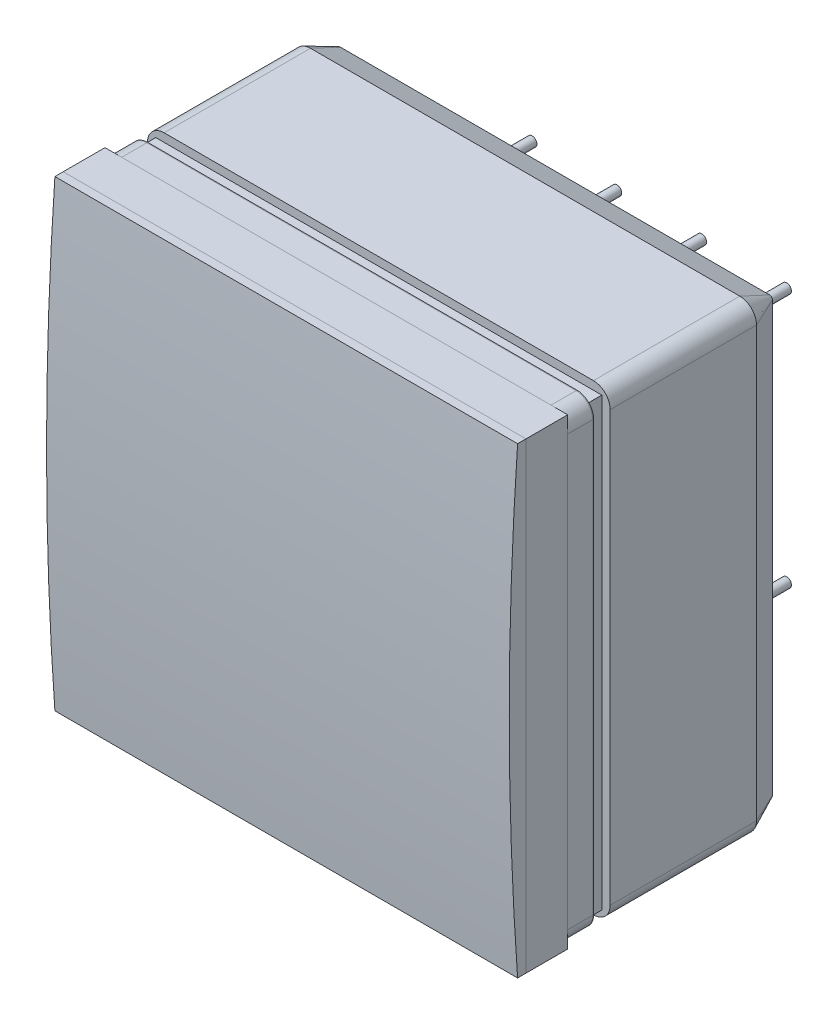
from build123d import *

# Parameters (mm, degrees)
METAL_CASE_AT_HV_DEPTH   = 8.76
SKETCH3_W                = 24.737677246
SKETCH3_H                = 24.830501551
PHOTOCATHODE_DEPTH       = 0.1
SKETCH5_W                = 26.7
SKETCH5_H                = 26.7
SKETCH5_W_2              = 23.2
SKETCH5_H_2              = 23.2
BOSS_EXTRUDE3_DEPTH      = 0.99
SKETCH6_W                = 23.2
SKETCH6_H                = 23.2
MIRRORED_SURFACE_DEPTH   = 0.05
FRONT_GLASS_DEPTH        = 1.5
SKETCH8_R                = 0.285
PINS_DEPTH               = 5.5
SKETCH9_W                = 1.403236588
SKETCH9_H                = 1.496318302
SKETCH9_W_2              = 1.502916358
SKETCH9_H_2              = 1.880163391
SKETCH9_W_3              = 1.432017479
SKETCH9_W_4              = 4.227959696
SKETCH9_W_5              = 1.836353851
SKETCH9_H_3              = 11.695124286
SKETCH9_H_4              = 4.871079897
SKETCH9_W_6              = 1.828629866
SKETCH9_H_5              = 1.71959621
SKETCH9_W_7              = 1.615933227
SKETCH9_W_8              = 1.365330314
SKETCH9_W_9              = 1.525378005
SKETCH9_H_6              = 1.496732956
SKETCH9_W_10             = 17.055037943
SKETCH9_H_7              = 1.444241572
SKETCH9_H_8              = 1.617700465
SKETCH9_H_9              = 1.513765196
SKETCH9_H_10             = 14.892572142
SKETCH9_H_11             = 1.645870576
SKETCH9_H_12             = 1.829290868
SKETCH9_W_11             = 1.140707165
SKETCH9_H_13             = 1.492116291
SKETCH9_W_12             = 1.724036428
SKETCH9_W_13             = 1.316199483
SKETCH9_H_14             = 1.570615298
SKETCH9_W_14             = 1.593474923
SKETCH9_W_15             = 1.889006141
SKETCH9_H_15             = 2.206356806
SKETCH9_W_16             = 6.877190486
SKETCH9_H_16             = 1.783898062
SKETCH9_W_17             = 1.759836844
SKETCH9_H_17             = 1.481039903
CUT_EXTRUDE1_DEPTH       = 5.5
RUBBER_DEPTH             = 1.79
RUBBER_TAPER             = 25
SKETCH17_W               = 27.7
SKETCH17_H               = 27.7
FILTER_2_DEPTH           = 2.5
COOKIE_CYLINDRICAL_DEPTH = 27.7


with BuildPart() as part:
    # Sketch2 → metal-case-at-HV (new body)
    with BuildSketch(Plane.XY.offset(-2.54)):
        with BuildLine():
            Line((1, 27.7), (26.7, 27.7))
            ThreePointArc((26.7, 27.7), (27.407106781, 27.407106781), (27.7, 26.7))
            Line((27.7, 26.7), (27.7, 1))
            ThreePointArc((27.7, 1), (27.407106781, 0.292893219), (26.7, 0))
            Line((26.7, 0), (1, 0))
            ThreePointArc((1, 0), (0.292893219, 0.292893219), (0, 1))
            Line((0, 1), (0, 26.7))
            ThreePointArc((0, 26.7), (0.292893219, 27.407106781), (1, 27.7))
        make_face()
    extrude(amount=-METAL_CASE_AT_HV_DEPTH)

    # Sketch3 → photocathode (add)
    with BuildSketch(Plane.XY.offset(-2.54)):
        with Locations((13.757175695, 13.780381772)):
            Rectangle(SKETCH3_W, SKETCH3_H)
    extrude(amount=PHOTOCATHODE_DEPTH)

    # Sketch5 → Boss-Extrude3 (add)
    with BuildSketch(Plane.XY.offset(-2.54)):
        with Locations((13.85, 13.85)):
            Rectangle(SKETCH5_W, SKETCH5_H)
        with Locations((13.85, 13.85)):
            Rectangle(SKETCH5_W_2, SKETCH5_H_2, mode=Mode.SUBTRACT)
    extrude(amount=BOSS_EXTRUDE3_DEPTH)

    # Sketch6 → mirrored-surface (add)
    with BuildSketch(Plane.XY.offset(-1.55)):
        with BuildLine():
            Line((1, 27.7), (26.7, 27.7))
            ThreePointArc((26.7, 27.7), (27.407106781, 27.407106781), (27.7, 26.7))
            Line((27.7, 26.7), (27.7, 1))
            ThreePointArc((27.7, 1), (27.407106781, 0.292893219), (26.7, 0))
            Line((26.7, 0), (1, 0))
            ThreePointArc((1, 0), (0.292893219, 0.292893219), (0, 1))
            Line((0, 1), (0, 26.7))
            ThreePointArc((0, 26.7), (0.292893219, 27.407106781), (1, 27.7))
        make_face()
        with Locations((13.85, 13.85)):
            Rectangle(SKETCH6_W, SKETCH6_H, mode=Mode.SUBTRACT)
    extrude(amount=MIRRORED_SURFACE_DEPTH)

    # Sketch8 → pins (add)
    with BuildSketch(Plane(origin=(0, 0, -11.3), x_dir=(-1, 0, 0), z_dir=(0, 0, -1))):
        with Locations((-24.01, 3.69)):
            Circle(SKETCH8_R)
        with Locations((-21.47, 3.69)):
            Circle(SKETCH8_R)
        with Locations((-18.93, 3.69)):
            Circle(SKETCH8_R)
        with Locations((-16.39, 3.69)):
            Circle(SKETCH8_R)
        with Locations((-13.85, 3.69)):
            Circle(SKETCH8_R)
        with Locations((-11.31, 3.69)):
            Circle(SKETCH8_R)
        with Locations((-8.77, 3.69)):
            Circle(SKETCH8_R)
        with Locations((-6.23, 3.69)):
            Circle(SKETCH8_R)
        with Locations((-3.69, 3.69)):
            Circle(SKETCH8_R)
        with Locations((-24.01, 6.23)):
            Circle(SKETCH8_R)
        with Locations((-21.47, 6.23)):
            Circle(SKETCH8_R)
        with Locations((-18.93, 6.23)):
            Circle(SKETCH8_R)
        with Locations((-16.39, 6.23)):
            Circle(SKETCH8_R)
        with Locations((-13.85, 6.23)):
            Circle(SKETCH8_R)
        with Locations((-11.31, 6.23)):
            Circle(SKETCH8_R)
        with Locations((-8.77, 6.23)):
            Circle(SKETCH8_R)
        with Locations((-6.23, 6.23)):
            Circle(SKETCH8_R)
        with Locations((-3.69, 6.23)):
            Circle(SKETCH8_R)
        with Locations((-24.01, 8.77)):
            Circle(SKETCH8_R)
        with Locations((-21.47, 8.77)):
            Circle(SKETCH8_R)
        with Locations((-18.93, 8.77)):
            Circle(SKETCH8_R)
        with Locations((-16.39, 8.77)):
            Circle(SKETCH8_R)
        with Locations((-13.85, 8.77)):
            Circle(SKETCH8_R)
        with Locations((-11.31, 8.77)):
            Circle(SKETCH8_R)
        with Locations((-8.77, 8.77)):
            Circle(SKETCH8_R)
        with Locations((-6.23, 8.77)):
            Circle(SKETCH8_R)
        with Locations((-3.69, 8.77)):
            Circle(SKETCH8_R)
        with Locations((-24.01, 11.31)):
            Circle(SKETCH8_R)
        with Locations((-21.47, 11.31)):
            Circle(SKETCH8_R)
        with Locations((-18.93, 11.31)):
            Circle(SKETCH8_R)
        with Locations((-16.39, 11.31)):
            Circle(SKETCH8_R)
        with Locations((-13.85, 11.31)):
            Circle(SKETCH8_R)
        with Locations((-11.31, 11.31)):
            Circle(SKETCH8_R)
        with Locations((-8.77, 11.31)):
            Circle(SKETCH8_R)
        with Locations((-6.23, 11.31)):
            Circle(SKETCH8_R)
        with Locations((-3.69, 11.31)):
            Circle(SKETCH8_R)
        with Locations((-24.01, 13.85)):
            Circle(SKETCH8_R)
        with Locations((-21.47, 13.85)):
            Circle(SKETCH8_R)
        with Locations((-18.93, 13.85)):
            Circle(SKETCH8_R)
        with Locations((-16.39, 13.85)):
            Circle(SKETCH8_R)
        with Locations((-13.85, 13.85)):
            Circle(SKETCH8_R)
        with Locations((-11.31, 13.85)):
            Circle(SKETCH8_R)
        with Locations((-8.77, 13.85)):
            Circle(SKETCH8_R)
        with Locations((-6.23, 13.85)):
            Circle(SKETCH8_R)
        with Locations((-3.69, 13.85)):
            Circle(SKETCH8_R)
        with Locations((-24.01, 16.39)):
            Circle(SKETCH8_R)
        with Locations((-21.47, 16.39)):
            Circle(SKETCH8_R)
        with Locations((-18.93, 16.39)):
            Circle(SKETCH8_R)
        with Locations((-16.39, 16.39)):
            Circle(SKETCH8_R)
        with Locations((-13.85, 16.39)):
            Circle(SKETCH8_R)
        with Locations((-11.31, 16.39)):
            Circle(SKETCH8_R)
        with Locations((-8.77, 16.39)):
            Circle(SKETCH8_R)
        with Locations((-6.23, 16.39)):
            Circle(SKETCH8_R)
        with Locations((-3.69, 16.39)):
            Circle(SKETCH8_R)
        with Locations((-24.01, 18.93)):
            Circle(SKETCH8_R)
        with Locations((-21.47, 18.93)):
            Circle(SKETCH8_R)
        with Locations((-18.93, 18.93)):
            Circle(SKETCH8_R)
        with Locations((-16.39, 18.93)):
            Circle(SKETCH8_R)
        with Locations((-13.85, 18.93)):
            Circle(SKETCH8_R)
        with Locations((-11.31, 18.93)):
            Circle(SKETCH8_R)
        with Locations((-8.77, 18.93)):
            Circle(SKETCH8_R)
        with Locations((-6.23, 18.93)):
            Circle(SKETCH8_R)
        with Locations((-3.69, 18.93)):
            Circle(SKETCH8_R)
        with Locations((-24.01, 21.47)):
            Circle(SKETCH8_R)
        with Locations((-21.47, 21.47)):
            Circle(SKETCH8_R)
        with Locations((-18.93, 21.47)):
            Circle(SKETCH8_R)
        with Locations((-16.39, 21.47)):
            Circle(SKETCH8_R)
        with Locations((-13.85, 21.47)):
            Circle(SKETCH8_R)
        with Locations((-11.31, 21.47)):
            Circle(SKETCH8_R)
        with Locations((-8.77, 21.47)):
            Circle(SKETCH8_R)
        with Locations((-6.23, 21.47)):
            Circle(SKETCH8_R)
        with Locations((-3.69, 21.47)):
            Circle(SKETCH8_R)
        with Locations((-24.01, 24.01)):
            Circle(SKETCH8_R)
        with Locations((-21.47, 24.01)):
            Circle(SKETCH8_R)
        with Locations((-18.93, 24.01)):
            Circle(SKETCH8_R)
        with Locations((-16.39, 24.01)):
            Circle(SKETCH8_R)
        with Locations((-13.85, 24.01)):
            Circle(SKETCH8_R)
        with Locations((-11.31, 24.01)):
            Circle(SKETCH8_R)
        with Locations((-8.77, 24.01)):
            Circle(SKETCH8_R)
        with Locations((-6.23, 24.01)):
            Circle(SKETCH8_R)
        with Locations((-3.69, 24.01)):
            Circle(SKETCH8_R)
    extrude(amount=PINS_DEPTH)

    # Sketch9 → Cut-Extrude1 (cut)
    with BuildSketch(Plane(origin=(0, 0, -16.8), x_dir=(-1, 0, 0), z_dir=(0, 0, -1))):
        with Locations((-21.480019138, 24.113026159)):
            Rectangle(SKETCH9_W, SKETCH9_H)
        with Locations((-16.559216808, 23.921103615)):
            Rectangle(SKETCH9_W_2, SKETCH9_H_2)
        with Locations((-11.149493241, 23.921103615)):
            Rectangle(SKETCH9_W_3, SKETCH9_H_2)
        with Locations((-5.093958278, 24.113026159)):
            Rectangle(SKETCH9_W_4, SKETCH9_H)
        with Locations((-23.96533774, 16.379524364)):
            Rectangle(SKETCH9_W_5, SKETCH9_H_3)
        with Locations((-23.96533774, 5.141508534)):
            Rectangle(SKETCH9_W_5, SKETCH9_H_4)
        with Locations((-18.879223075, 21.590151656)):
            Rectangle(SKETCH9_W_6, SKETCH9_H_5)
        with Locations((-13.758710646, 21.590151656)):
            Rectangle(SKETCH9_W_7, SKETCH9_H_5)
        with Locations((-8.69295177, 21.590151656)):
            Rectangle(SKETCH9_W_8, SKETCH9_H_5)
        with Locations((-3.742667433, 21.478720029)):
            Rectangle(SKETCH9_W_9, SKETCH9_H_6)
        with Locations((-13.896295437, 19.092329501)):
            Rectangle(SKETCH9_W_10, SKETCH9_H_7)
        with Locations((-13.896295437, 13.951861682)):
            Rectangle(SKETCH9_W_10, SKETCH9_H_8)
        with Locations((-13.896295437, 8.881967989)):
            Rectangle(SKETCH9_W_10, SKETCH9_H_9)
        with Locations((-3.742667433, 10.152254656)):
            Rectangle(SKETCH9_W_9, SKETCH9_H_10)
        with Locations((-18.879223075, 16.504452811)):
            Rectangle(SKETCH9_W_6, SKETCH9_H_11)
        with Locations((-13.758710646, 16.504452811)):
            Rectangle(SKETCH9_W_7, SKETCH9_H_11)
        with Locations((-8.69295177, 16.504452811)):
            Rectangle(SKETCH9_W_8, SKETCH9_H_11)
        with Locations((-8.69295177, 11.446607655)):
            Rectangle(SKETCH9_W_8, SKETCH9_H_12)
        with Locations((-8.805263345, 6.274958053)):
            Rectangle(SKETCH9_W_11, SKETCH9_H_13)
        with Locations((-14.11249599, 6.274958053)):
            Rectangle(SKETCH9_W_12, SKETCH9_H_13)
        with Locations((-13.908577517, 11.31726987)):
            Rectangle(SKETCH9_W_13, SKETCH9_H_14)
        with Locations((-18.996800547, 11.446607655)):
            Rectangle(SKETCH9_W_14, SKETCH9_H_12)
        with Locations((-18.879223075, 6.274958053)):
            Rectangle(SKETCH9_W_6, SKETCH9_H_13)
        with Locations((-21.479311338, 3.809146988)):
            Rectangle(SKETCH9_W_15, SKETCH9_H_15)
        with Locations((-13.872079744, 3.597917616)):
            Rectangle(SKETCH9_W_16, SKETCH9_H_16)
        with Locations((-6.657233785, 3.749346696)):
            Rectangle(SKETCH9_W_17, SKETCH9_H_17)
    extrude(amount=-CUT_EXTRUDE1_DEPTH, mode=Mode.SUBTRACT)


with BuildPart() as body_2:
    # Sketch7 → front-glass (new body)
    with BuildSketch(Plane.XY.offset(-1.5)):
        with BuildLine():
            Line((1, 27.7), (26.7, 27.7))
            ThreePointArc((26.7, 27.7), (27.407106781, 27.407106781), (27.7, 26.7))
            Line((27.7, 26.7), (27.7, 1))
            ThreePointArc((27.7, 1), (27.407106781, 0.292893219), (26.7, 0))
            Line((26.7, 0), (1, 0))
            ThreePointArc((1, 0), (0.292893219, 0.292893219), (0, 1))
            Line((0, 1), (0, 26.7))
            ThreePointArc((0, 26.7), (0.292893219, 27.407106781), (1, 27.7))
        make_face()
    extrude(amount=FRONT_GLASS_DEPTH)


with BuildPart() as body_3:
    # Sketch10 → rubber (new body)
    with BuildSketch(Plane(origin=(0, 0, -11.3), x_dir=(-1, 0, 0), z_dir=(0, 0, -1))):
        with BuildLine():
            ThreePointArc((-26.7, 27.7), (-27.407106781, 27.407106781), (-27.7, 26.7))
            Line((-27.7, 26.7), (-27.7, 1))
            ThreePointArc((-27.7, 1), (-27.407106781, 0.292893219), (-26.7, 0))
            Line((-26.7, 0), (-1, 0))
            ThreePointArc((-1, 0), (-0.292893219, 0.292893219), (0, 1))
            Line((0, 1), (0, 26.7))
            ThreePointArc((0, 26.7), (-0.292893219, 27.407106781), (-1, 27.7))
            Line((-1, 27.7), (-26.7, 27.7))
        make_face()
    extrude(amount=RUBBER_DEPTH, taper=RUBBER_TAPER)


with BuildPart() as body_4:
    # Sketch17 → filter 2 (new body)
    with BuildSketch(Plane.XY):
        with Locations((13.85, 13.85)):
            Rectangle(SKETCH17_W, SKETCH17_H)
    extrude(amount=FILTER_2_DEPTH)


with BuildPart() as body_5:
    # Sketch14 → cookie-cylindrical (new body)
    with BuildSketch(Plane(origin=(0, 0, 0), x_dir=(0, 0, -1), z_dir=(1, 0, 0))):
        with BuildLine():
            Line((-2.5, 27.7), (-2.5, 0))
            Line((-2.5, 0), (-3, 0))
            ThreePointArc((-3, 0), (-3.374959299, 6.920488834), (-3.5, 13.85))
            ThreePointArc((-3.5, 13.85), (-3.374959299, 20.779511166), (-3, 27.7))
            Line((-3, 27.7), (-2.5, 27.7))
        make_face()
    extrude(amount=COOKIE_CYLINDRICAL_DEPTH)


solid = Compound([part.part, body_2.part, body_3.part, body_4.part, body_5.part])
